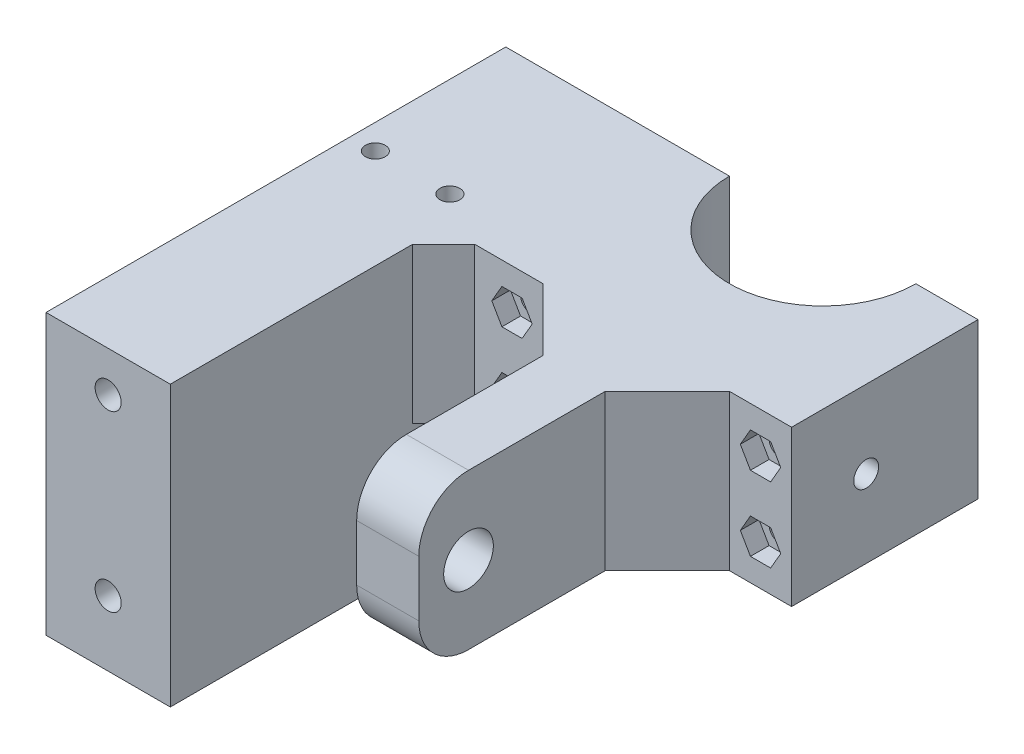
from build123d import *

# Parameters (mm, degrees)
BOSS_EXTRUDE1_DEPTH = 25
SKETCH2_R           = 4
CUT_EXTRUDE1_DEPTH  = 88.229582138
SKETCH3_R           = 1.6
CUT_EXTRUDE2_DEPTH  = 79.755553628
CUT_EXTRUDE3_DEPTH  = 3
FILLET2_R           = 8
CHAMFER2_SIZE       = 10
SKETCH5_W           = 30
SKETCH5_H           = 25
BOSS_EXTRUDE2_DEPTH = 26
SKETCH6_W           = 20.004484435
SKETCH6_H           = 25
BOSS_EXTRUDE3_DEPTH = 44
SKETCH7_W           = 10.4
SKETCH7_H           = 20.4
CUT_EXTRUDE4_DEPTH  = 23
SKETCH9_W           = 20.004484435
SKETCH9_H           = 44
SKETCH9_W_2         = 10.4
SKETCH9_H_2         = 20.4
BOSS_EXTRUDE4_DEPTH = 20
SKETCH10_R          = 2.1
CUT_EXTRUDE6_DEPTH  = 93.726686192
CHAMFER5_SIZE       = 5
SKETCH11_R          = 2
CUT_EXTRUDE7_DEPTH  = 115.564392374
SKETCH12_W          = 20.004484435
SKETCH12_H          = 20
SKETCH12_R          = 2.1
BOSS_EXTRUDE5_DEPTH = 30
SKETCH13_R          = 1.6
CUT_EXTRUDE8_DEPTH  = 107.048283023


with BuildPart() as part:
    # Sketch1 → Boss-Extrude1 (new body)
    with BuildSketch(Plane(origin=(0, 0, 0), x_dir=(1, 0, 0), z_dir=(0, 1, 0))):
        with BuildLine():
            Line((-13.972375691, -8), (-23.972375691, -8))
            Line((-23.972375691, -8), (-23.972375691, -38))
            Line((-23.972375691, -38), (-3.972375691, -38))
            Line((-3.972375691, -38), (-3.972375691, -78))
            Line((-3.972375691, -78), (6.027624309, -78))
            Line((6.027624309, -78), (6.027624309, -38))
            Line((6.027624309, -38), (26.027624309, -38))
            Line((26.027624309, -38), (26.027624309, -8))
            Line((26.027624309, -8), (16.027624309, -8))
            ThreePointArc((16.027624309, -8), (1.027624309, -23), (-13.972375691, -8))
        make_face()
    extrude(amount=BOSS_EXTRUDE1_DEPTH)

    # Sketch2 → Cut-Extrude1 (cut, through all)
    with BuildSketch(Plane.ZY.offset(3.972375691)):
        with Locations((70, 12.5)):
            Circle(SKETCH2_R)
    extrude(amount=-CUT_EXTRUDE1_DEPTH, mode=Mode.SUBTRACT)

    # Sketch3 → Cut-Extrude2 (cut, through all)
    with BuildSketch(Plane(origin=(0, 0, 8), x_dir=(-1, 0, 0), z_dir=(0, 0, -1))):
        with Locations((-21.027624309, 6.5)):
            Circle(SKETCH3_R)
        with Locations((-21.027624309, 18.5)):
            Circle(SKETCH3_R)
        with Locations((18.972375691, 6.5)):
            Circle(SKETCH3_R)
        with Locations((18.972375691, 18.5)):
            Circle(SKETCH3_R)
    extrude(amount=-CUT_EXTRUDE2_DEPTH, mode=Mode.SUBTRACT)

    # Sketch4 → Cut-Extrude3 (cut)
    with BuildSketch(Plane.XY.offset(38)):
        Polygon((24.277624309, 18.5), (22.652624309, 21.314582562), (19.402624309, 21.314582562), (17.777624309, 18.5), (19.402624309, 15.685417438), (22.652624309, 15.685417438), align=None)
        Polygon((24.277624309, 6.5), (22.652624309, 9.314582562), (19.402624309, 9.314582562), (17.777624309, 6.5), (19.402624309, 3.685417438), (22.652624309, 3.685417438), align=None)
        Polygon((-15.722375691, 18.5), (-17.347375691, 21.314582562), (-20.597375691, 21.314582562), (-22.222375691, 18.5), (-20.597375691, 15.685417438), (-17.347375691, 15.685417438), align=None)
        Polygon((-15.722375691, 6.5), (-17.347375691, 9.314582562), (-20.597375691, 9.314582562), (-22.222375691, 6.5), (-20.597375691, 3.685417438), (-17.347375691, 3.685417438), align=None)
    extrude(amount=-CUT_EXTRUDE3_DEPTH, mode=Mode.SUBTRACT)

    # Fillet2
    fillet2_edges = [part.edges().sort_by_distance(p)[0] for p in [
        (1.027624309, 0, 78),
        (1.027624309, 25, 78),
    ]]
    fillet(fillet2_edges, radius=FILLET2_R)

    # Chamfer2
    chamfer2_edges = [part.edges().sort_by_distance(p)[0] for p in [
        (6.027624309, 12.5, 38),
        (-3.972375691, 12.5, 38),
    ]]
    chamfer(chamfer2_edges, length=CHAMFER2_SIZE)

    # Sketch5 → Boss-Extrude2 (add)
    with BuildSketch(Plane.ZY.offset(23.972375691)):
        with Locations((23, 12.5)):
            Rectangle(SKETCH5_W, SKETCH5_H)
    extrude(amount=BOSS_EXTRUDE2_DEPTH)

    # Sketch6 → Boss-Extrude3 (add)
    with BuildSketch(Plane.XY.offset(38)):
        with Locations((-39.970133473, 12.5)):
            Rectangle(SKETCH6_W, SKETCH6_H)
    extrude(amount=BOSS_EXTRUDE3_DEPTH)

    # Sketch7 → Cut-Extrude4 (cut)
    with BuildSketch(Plane.XZ):
        with Locations((-39.970133474, 66)):
            Rectangle(SKETCH7_W, SKETCH7_H)
    extrude(amount=-CUT_EXTRUDE4_DEPTH, mode=Mode.SUBTRACT)

    # Sketch9 → Boss-Extrude4 (add)
    with BuildSketch(Plane.XZ):
        with Locations((-39.970133473, 60)):
            Rectangle(SKETCH9_W, SKETCH9_H)
        with Locations((-39.970133474, 66)):
            Rectangle(SKETCH9_W_2, SKETCH9_H_2, mode=Mode.SUBTRACT)
    extrude(amount=BOSS_EXTRUDE4_DEPTH)

    # Sketch10 → Cut-Extrude6 (cut, through all)
    with BuildSketch(Plane.XY.offset(82)):
        with Locations((-39.970133474, -9.5)):
            Circle(SKETCH10_R)
        with Locations((-39.970133474, 18.5)):
            Circle(SKETCH10_R)
    extrude(amount=-CUT_EXTRUDE6_DEPTH, mode=Mode.SUBTRACT)

    # Chamfer5
    chamfer5_edges = [part.edges().sort_by_distance(p)[0] for p in [
        (-29.967891256, 12.5, 38),
    ]]
    chamfer(chamfer5_edges, length=CHAMFER5_SIZE)

    # Sketch11 → Cut-Extrude7 (cut, through all)
    with BuildSketch(Plane(origin=(26.027624309, 0, 0), x_dir=(0, 0, -1), z_dir=(1, 0, 0))):
        with Locations((-26, 12.5)):
            Circle(SKETCH11_R)
    extrude(amount=-CUT_EXTRUDE7_DEPTH, mode=Mode.SUBTRACT)

    # Sketch12 → Boss-Extrude5 (add)
    with BuildSketch(Plane(origin=(0, 0, 38), x_dir=(-1, 0, 0), z_dir=(0, 0, -1))):
        with Locations((39.970133473, -10)):
            Rectangle(SKETCH12_W, SKETCH12_H)
        with Locations(Location((39.970133474, -9.5, 0), (0, 0, 180))):
            Circle(SKETCH12_R, mode=Mode.SUBTRACT)
    extrude(amount=BOSS_EXTRUDE5_DEPTH)

    # Sketch13 → Cut-Extrude8 (cut, through all)
    with BuildSketch(Plane.XZ.offset(20)):
        with Locations(Location((-33.970133474, 33, 0), (0, 0, 270))):
            Circle(SKETCH13_R)
        with Locations(Location((-45.970133474, 33, 0), (0, 0, 270))):
            Circle(SKETCH13_R)
    extrude(amount=-CUT_EXTRUDE8_DEPTH, mode=Mode.SUBTRACT)


solid = part.part
